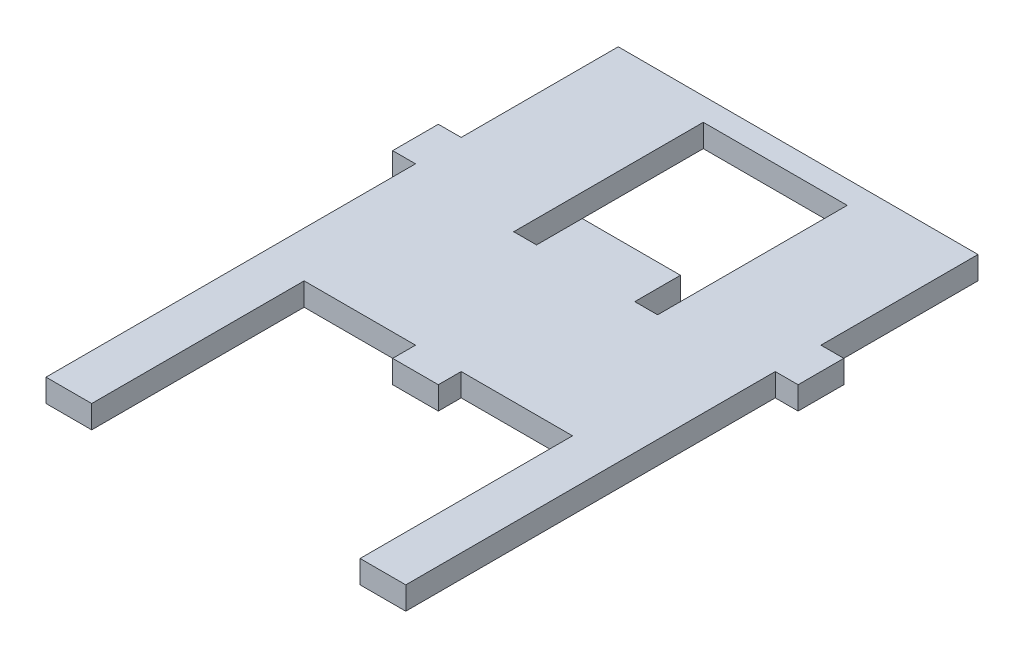
from build123d import *

# Parameters (mm, degrees)
SKETCH1_W           = 100
SKETCH1_H           = 100
BOSS_EXTRUDE1_DEPTH = 6.35
SKETCH2_W           = 12.7
SKETCH2_H           = 6.35
BOSS_EXTRUDE2_DEPTH = 6.35
CIRPATTERN1_COUNT   = 3
CIRPATTERN1_ANGLE   = 180
SKETCH4_W           = 12.7
SKETCH4_H           = 6.35
BOSS_EXTRUDE3_DEPTH = 59.05
SKETCH5_W           = 40
SKETCH5_H           = 40
CUT_EXTRUDE1_DEPTH  = 123.91276378
SKETCH6_W           = 6.35
SKETCH6_H           = 12.7
CUT_EXTRUDE2_DEPTH  = 123.91276378


with BuildPart() as part:
    # Sketch1 → Boss-Extrude1 (new body)
    with BuildSketch(Plane(origin=(0, 0, 0), x_dir=(1, 0, 0), z_dir=(0, 1, 0))):
        Rectangle(SKETCH1_W, SKETCH1_H)
    extrude(amount=BOSS_EXTRUDE1_DEPTH)

    # Sketch2 → Boss-Extrude2 (add)
    with BuildSketch(Plane.ZY.offset(50)):
        with Locations((0, 3.175)):
            Rectangle(SKETCH2_W, SKETCH2_H)
    boss_extrude2 = extrude(amount=BOSS_EXTRUDE2_DEPTH)

    # CirPattern1: Boss-Extrude2 ×3 about axis
    cirpattern1_axis = Axis((0, 6.35, 0), (0, 1, 0))
    for i in range(1, CIRPATTERN1_COUNT):
        add(boss_extrude2.rotate(cirpattern1_axis, i * CIRPATTERN1_ANGLE / (CIRPATTERN1_COUNT - 1)))

    # Sketch4 → Boss-Extrude3 (add)
    with BuildSketch(Plane.XY.offset(50)):
        with Locations((-43.65, 3.175)):
            Rectangle(SKETCH4_W, SKETCH4_H)
    boss_extrude3 = extrude(amount=BOSS_EXTRUDE3_DEPTH)

    # Mirror1: Boss-Extrude3 across plane
    add(boss_extrude3.mirror(Plane(origin=(0, 0, 0), x_dir=(0, 0, 1), z_dir=(1, 0, 0))))

    # Sketch5 → Cut-Extrude1 (cut, through all)
    with BuildSketch(Plane(origin=(0, 6.35, 0), x_dir=(1, 0, 0), z_dir=(0, 1, 0))):
        with Locations((0, 23.65)):
            Rectangle(SKETCH5_W, SKETCH5_H)
    extrude(amount=-CUT_EXTRUDE1_DEPTH, mode=Mode.SUBTRACT)

    # Sketch6 → Cut-Extrude2 (cut, through all)
    with BuildSketch(Plane(origin=(0, 6.35, 0), x_dir=(1, 0, 0), z_dir=(0, 1, 0))):
        with Locations((-16.825, -2.7)):
            Rectangle(SKETCH6_W, SKETCH6_H)
    cut_extrude2 = extrude(amount=-CUT_EXTRUDE2_DEPTH, mode=Mode.SUBTRACT)

    # Mirror2: Cut-Extrude2 across plane
    add(cut_extrude2.mirror(Plane(origin=(0, 0, 0), x_dir=(0, 0, 1), z_dir=(1, 0, 0))), mode=Mode.SUBTRACT)


solid = part.part
